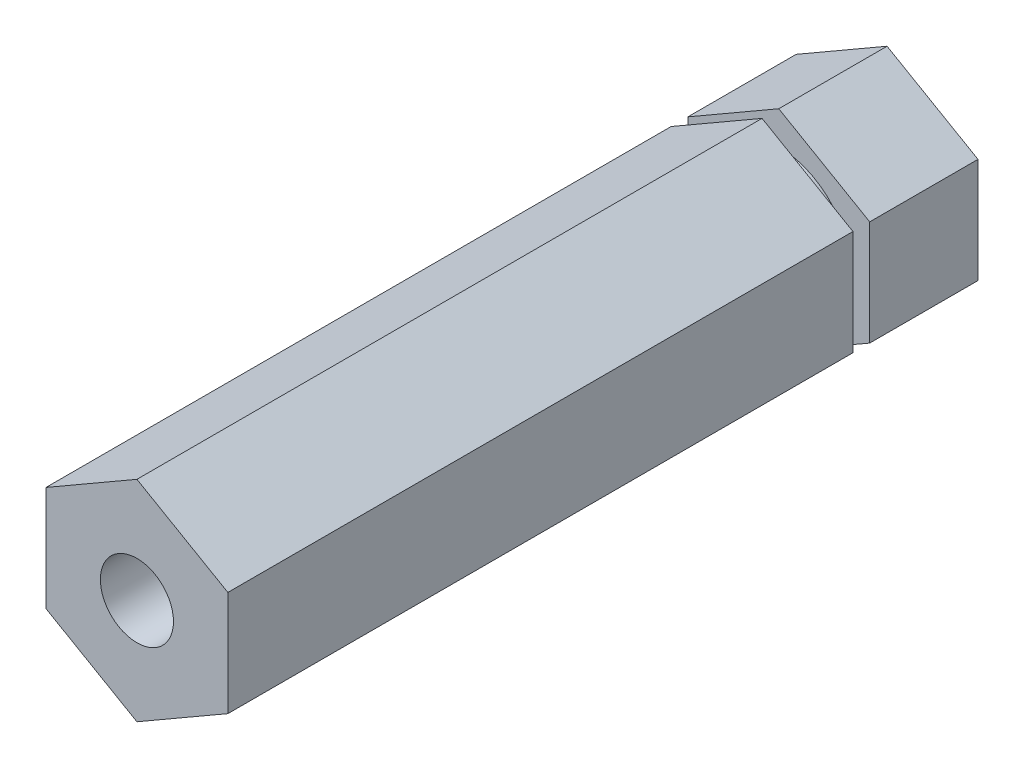
from build123d import *

# Parameters (mm, degrees)
BOSS_EXTRUDE1_DEPTH         = 26.19375
F_1_4_20_TAPPED_HOLE1_D     = 5.1054
F_1_4_20_TAPPED_HOLE1_DEPTH = 19.05
F_1_4_20_TAPPED_HOLE1_TIP   = 1.533816902
SKETCH5_W                   = 1.1684
SKETCH5_H                   = 4.843148419


with BuildPart() as part:
    # Sketch1 → Boss-Extrude1 (new body, symmetric)
    with BuildSketch(Plane.XY):
        Polygon((-6.35, 3.666174209), (-6.35, -3.666174209), (0, -7.332348419), (6.35, -3.666174209), (6.35, 3.666174209), (0, 7.332348419), align=None)
    extrude(amount=BOSS_EXTRUDE1_DEPTH, both=True)

    # 1/4-20 Tapped Hole1
    with Locations(Plane.XY.offset(26.19375)):
        with Locations((0, 0)):
            Hole(F_1_4_20_TAPPED_HOLE1_D / 2, depth=F_1_4_20_TAPPED_HOLE1_DEPTH)
            with Locations((0, 0, -(F_1_4_20_TAPPED_HOLE1_DEPTH + F_1_4_20_TAPPED_HOLE1_TIP / 2))):  # 118° drill point
                Cone(0, F_1_4_20_TAPPED_HOLE1_D / 2, F_1_4_20_TAPPED_HOLE1_TIP, mode=Mode.SUBTRACT)

    # Sketch5 → Cut-Revolve1 (revolve, cut)
    with BuildSketch(Plane(origin=(0, 0, 0), x_dir=(0, 0, -1), z_dir=(1, 0, 0))):
        with Locations((18.0467, 7.45077421)):
            Rectangle(SKETCH5_W, SKETCH5_H)
    revolve(axis=Axis((0, 0, -26.19375), (0, 0, 1)), mode=Mode.SUBTRACT)


solid = part.part
